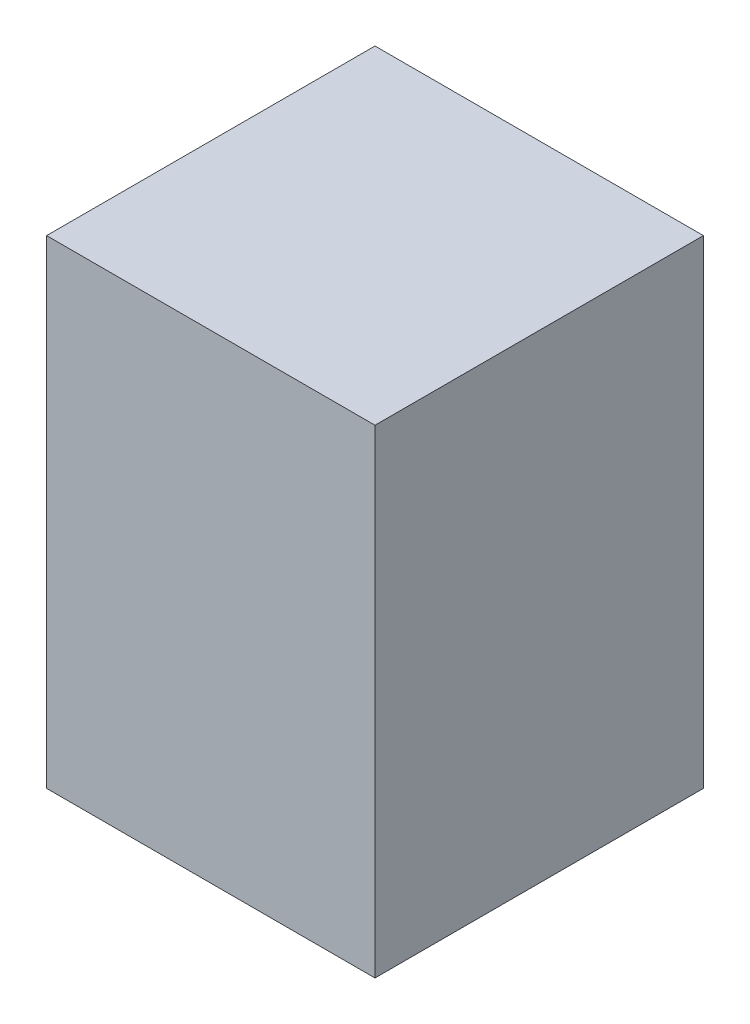
from build123d import *

# Parameters (mm, degrees)
SKETCH1_W                = 343
SKETCH1_H                = 343
BOSS_EXTRUDE1_DEPTH      = 440
BOSS_EXTRUDE1_DEPTH_BACK = 60


with BuildPart() as part:
    # Sketch1 → Boss-Extrude1 (new body, two sides)
    with BuildSketch(Plane(origin=(0, 0, 0), x_dir=(1, 0, 0), z_dir=(0, 1, 0))) as boss_extrude1_sk:
        Rectangle(SKETCH1_W, SKETCH1_H)
    extrude(amount=BOSS_EXTRUDE1_DEPTH)
    extrude(boss_extrude1_sk.sketch, amount=-BOSS_EXTRUDE1_DEPTH_BACK)


solid = part.part
